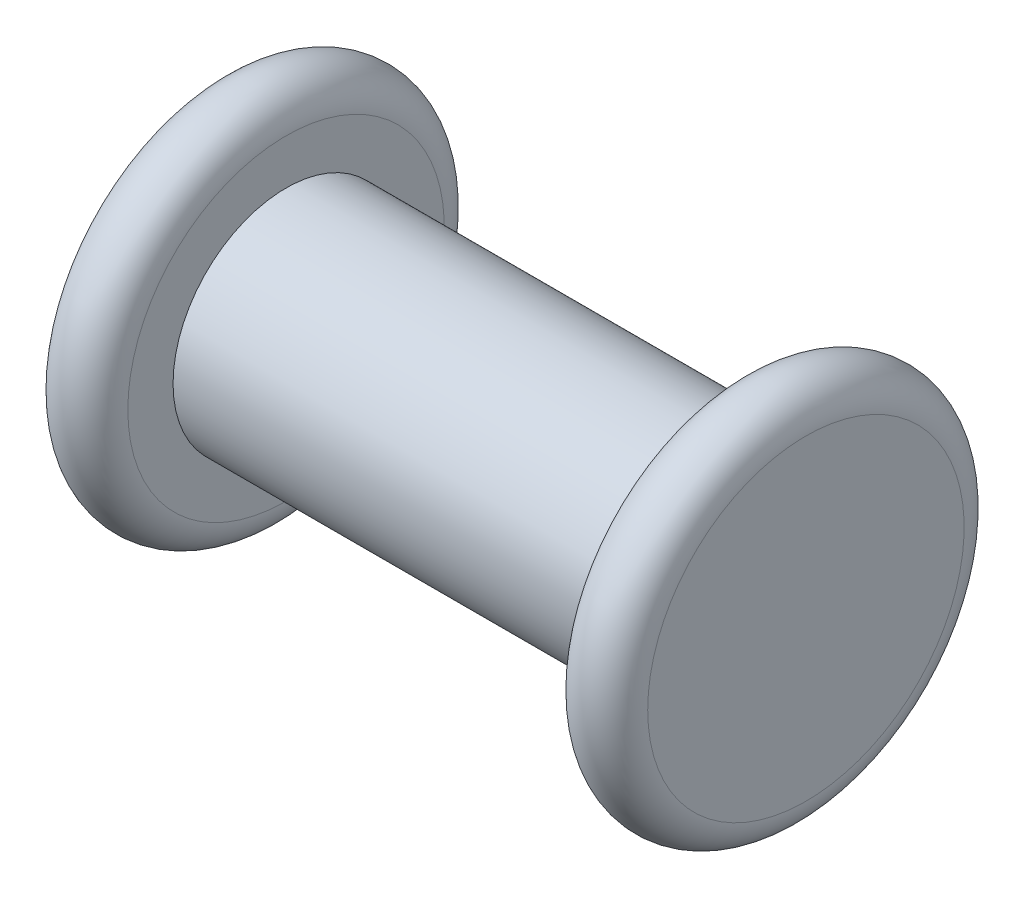
from build123d import *


with BuildPart() as part:
    # Sketch1 → Base-Revolve (revolve)
    with BuildSketch(Plane.XY):
        with BuildLine():
            Line((-8.255, 0), (-8.255, 4.445))
            ThreePointArc((-8.255, 4.445), (-7.3025, 5.3975), (-6.35, 4.445))
            Line((-6.35, 4.445), (-6.35, 3.175))
            Line((-6.35, 3.175), (6.35, 3.175))
            Line((6.35, 3.175), (6.35, 4.445))
            ThreePointArc((6.35, 4.445), (7.3025, 5.3975), (8.255, 4.445))
            Line((8.255, 4.445), (8.255, 0))
            Line((8.255, 0), (-8.255, 0))
        make_face()
    revolve(axis=Axis((-39.242848629, 0, 0), (1, 0, 0)))


solid = part.part
